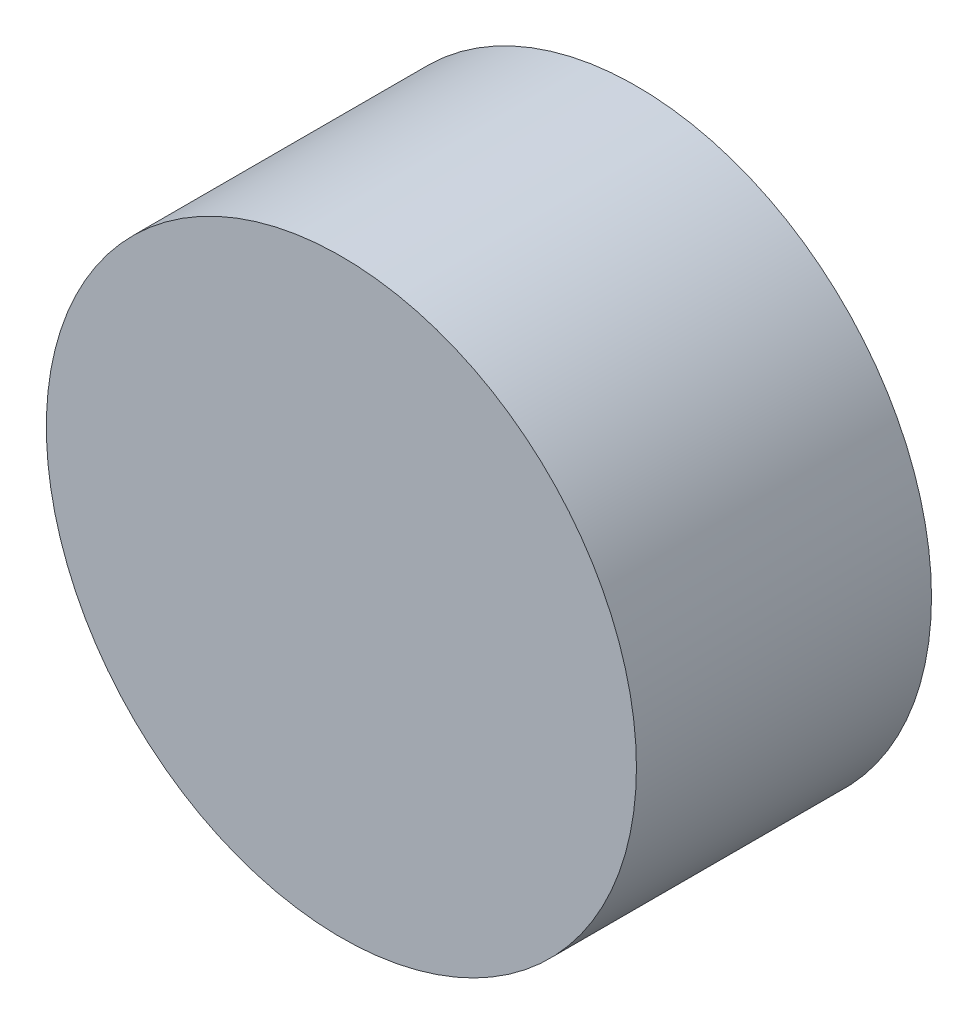
from build123d import *

# Parameters (mm, degrees)
SKETCH1_R           = 2
BOSS_EXTRUDE1_DEPTH = 1


with BuildPart() as part:
    # Sketch1 → Boss-Extrude1 (new body, symmetric)
    with BuildSketch(Plane.XY):
        Circle(SKETCH1_R)
    extrude(amount=BOSS_EXTRUDE1_DEPTH, both=True)


solid = part.part
